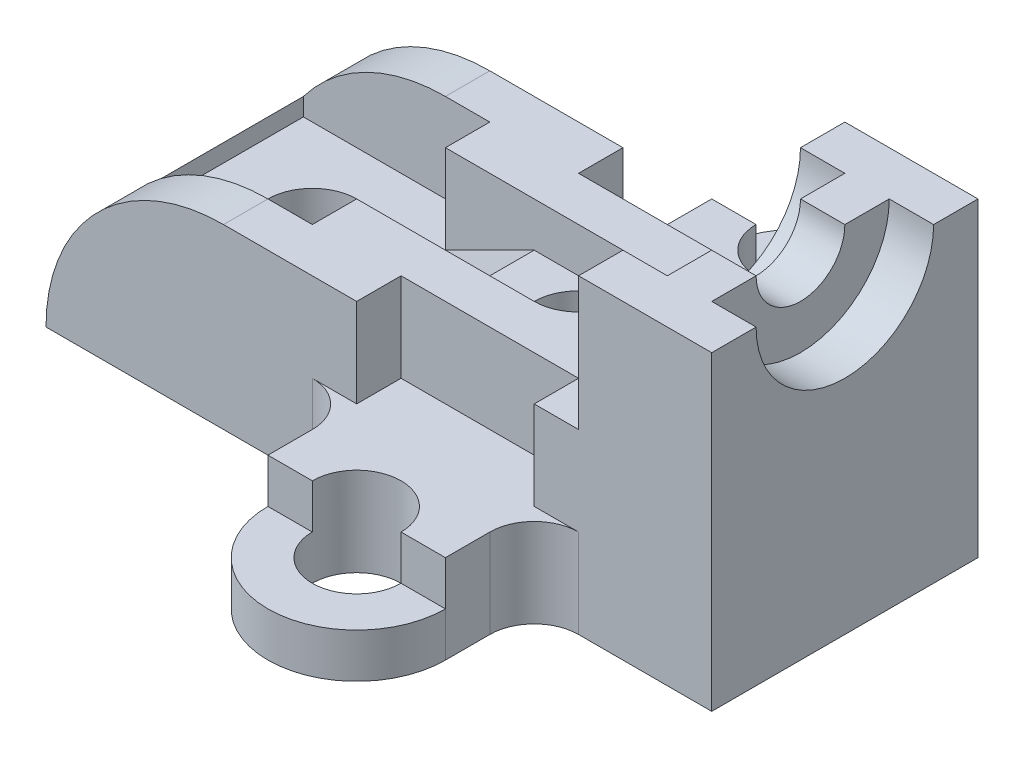
from build123d import *

# Parameters (mm, degrees)
BOSS_EXTRUDE1_DEPTH = 60
CUT_EXTRUDE1_DEPTH  = 10
CUT_EXTRUDE2_DEPTH  = 10
CUT_EXTRUDE3_DEPTH  = 30
SKETCH7_R           = 10
CUT_EXTRUDE5_DEPTH  = 75
SKETCH8_R           = 10
CUT_EXTRUDE6_DEPTH  = 75
SKETCH9_W           = 42
SKETCH9_H           = 40
CUT_EXTRUDE8_DEPTH  = 65
CUT_EXTRUDE9_DEPTH  = 10
CUT_EXTRUDE10_DEPTH = 20
SKETCH12_W          = 40
SKETCH12_H          = 10
CUT_EXTRUDE11_DEPTH = 20
BOSS_EXTRUDE2_DEPTH = 20
SKETCH14_R          = 10
CUT_EXTRUDE14_DEPTH = 20
CUT_EXTRUDE15_DEPTH = 10
BOSS_EXTRUDE3_DEPTH = 20
SKETCH18_R          = 10
CUT_EXTRUDE16_DEPTH = 20
CUT_EXTRUDE17_DEPTH = 10


with BuildPart() as part:
    # Sketch2 → Boss-Extrude1 (new body)
    with BuildSketch(Plane.XY):
        with BuildLine():
            Line((0, 0), (150, 0))
            Line((150, 0), (150, 70))
            Line((150, 70), (120, 70))
            Line((120, 70), (120, 40))
            Line((120, 40), (40, 40))
            ThreePointArc((40, 40), (11.715728753, 28.284271247), (0, 0))
        make_face()
    extrude(amount=BOSS_EXTRUDE1_DEPTH)

    # Sketch4 → Cut-Extrude1 (cut)
    with BuildSketch(Plane(origin=(150, 0, 0), x_dir=(0, 0, -1), z_dir=(1, 0, 0))):
        with BuildLine():
            Line((-50, 70), (-40, 70))
            ThreePointArc((-40, 70), (-30, 60), (-20, 70))
            Line((-20, 70), (-10, 70))
            ThreePointArc((-10, 70), (-30, 50), (-50, 70))
        make_face()
    extrude(amount=-CUT_EXTRUDE1_DEPTH, mode=Mode.SUBTRACT)

    # Sketch5 → Cut-Extrude2 (cut)
    with BuildSketch(Plane.ZY.offset(-120)):
        with BuildLine():
            Line((10, 70), (20, 70))
            ThreePointArc((20, 70), (30, 60), (40, 70))
            Line((40, 70), (50, 70))
            ThreePointArc((50, 70), (30, 50), (10, 70))
        make_face()
    extrude(amount=-CUT_EXTRUDE2_DEPTH, mode=Mode.SUBTRACT)

    # Sketch6 → Cut-Extrude3 (cut)
    with BuildSketch(Plane.ZY.offset(-120)):
        with BuildLine():
            Line((20, 70), (40, 70))
            ThreePointArc((40, 70), (30, 60), (20, 70))
        make_face()
    extrude(amount=-CUT_EXTRUDE3_DEPTH, mode=Mode.SUBTRACT)

    # Sketch7 → Cut-Extrude5 (cut)
    with BuildSketch(Plane(origin=(0, 40, 0), x_dir=(1, 0, 0), z_dir=(0, 1, 0))):
        with Locations((90, -30)):
            Circle(SKETCH7_R)
    extrude(amount=-CUT_EXTRUDE5_DEPTH, mode=Mode.SUBTRACT)

    # Sketch8 → Cut-Extrude6 (cut)
    with BuildSketch(Plane.XZ):
        with Locations((30, 30)):
            Circle(SKETCH8_R)
    extrude(amount=-CUT_EXTRUDE6_DEPTH, mode=Mode.SUBTRACT)

    # Sketch9 → Cut-Extrude8 (cut)
    with BuildSketch(Plane(origin=(0, 20, 0), x_dir=(1, 0, 0), z_dir=(0, 1, 0))):
        with Locations((29, -30)):
            Rectangle(SKETCH9_W, SKETCH9_H)
    extrude(amount=CUT_EXTRUDE8_DEPTH, mode=Mode.SUBTRACT)

    # Sketch10 → Cut-Extrude9 (cut)
    with BuildSketch(Plane(origin=(0, 40, 0), x_dir=(1, 0, 0), z_dir=(0, 1, 0))):
        with BuildLine():
            Line((90, -20), (50, -20))
            Line((50, -20), (50, -40))
            Line((50, -40), (90, -40))
            ThreePointArc((90, -40), (80, -30), (90, -20))
        make_face()
    extrude(amount=-CUT_EXTRUDE9_DEPTH, mode=Mode.SUBTRACT)

    # Sketch11 → Cut-Extrude10 (cut)
    with BuildSketch(Plane.XY.offset(20)):
        Polygon((50, 20), (70, 30), (50, 30), align=None)
    extrude(amount=CUT_EXTRUDE10_DEPTH, mode=Mode.SUBTRACT)

    # Sketch12 → Cut-Extrude11 (cut)
    with BuildSketch(Plane(origin=(0, 40, 0), x_dir=(1, 0, 0), z_dir=(0, 1, 0))):
        with Locations((90, -55)):
            Rectangle(SKETCH12_W, SKETCH12_H)
        with Locations((90, -5)):
            Rectangle(SKETCH12_W, SKETCH12_H)
    extrude(amount=-CUT_EXTRUDE11_DEPTH, mode=Mode.SUBTRACT)

    # Sketch13 → Boss-Extrude2 (add)
    with BuildSketch(Plane(origin=(0, 0, 0), x_dir=(1, 0, 0), z_dir=(0, 1, 0))):
        with BuildLine():
            Line((70, -70), (70, -80))
            ThreePointArc((70, -80), (90, -100), (110, -80))
            Line((110, -80), (110, -70))
            ThreePointArc((110, -70), (112.928932188, -62.928932188), (120, -60))
            Line((120, -60), (60, -60))
            ThreePointArc((60, -60), (67.071067812, -62.928932188), (70, -70))
        make_face()
    extrude(amount=BOSS_EXTRUDE2_DEPTH)

    # Sketch14 → Cut-Extrude14 (cut)
    with BuildSketch(Plane(origin=(0, 20, 0), x_dir=(1, 0, 0), z_dir=(0, 1, 0))):
        with Locations((90, -80)):
            Circle(SKETCH14_R)
    extrude(amount=-CUT_EXTRUDE14_DEPTH, mode=Mode.SUBTRACT)

    # Sketch15 → Cut-Extrude15 (cut)
    with BuildSketch(Plane(origin=(0, 20, 0), x_dir=(1, 0, 0), z_dir=(0, 1, 0))):
        with BuildLine():
            Line((70, -80), (80, -80))
            ThreePointArc((80, -80), (90, -90), (100, -80))
            Line((100, -80), (110, -80))
            ThreePointArc((110, -80), (90, -100), (70, -80))
        make_face()
    extrude(amount=-CUT_EXTRUDE15_DEPTH, mode=Mode.SUBTRACT)

    # Sketch17 → Boss-Extrude3 (add)
    with BuildSketch(Plane.XZ):
        with BuildLine():
            Line((110, -10), (110, -20))
            ThreePointArc((110, -20), (90, -40), (70, -20))
            Line((70, -20), (70, -10))
            ThreePointArc((70, -10), (67.071067812, -2.928932188), (60, 0))
            Line((60, 0), (120, 0))
            ThreePointArc((120, 0), (112.928932188, -2.928932188), (110, -10))
        make_face()
    extrude(amount=-BOSS_EXTRUDE3_DEPTH)

    # Sketch18 → Cut-Extrude16 (cut)
    with BuildSketch(Plane(origin=(0, 20, 0), x_dir=(1, 0, 0), z_dir=(0, 1, 0))):
        with Locations((90, 20)):
            Circle(SKETCH18_R)
    extrude(amount=-CUT_EXTRUDE16_DEPTH, mode=Mode.SUBTRACT)

    # Sketch19 → Cut-Extrude17 (cut)
    with BuildSketch(Plane(origin=(0, 20, 0), x_dir=(1, 0, 0), z_dir=(0, 1, 0))):
        with BuildLine():
            Line((100, 20), (110, 20))
            ThreePointArc((110, 20), (90, 40), (70, 20))
            Line((70, 20), (80, 20))
            ThreePointArc((80, 20), (90, 30), (100, 20))
        make_face()
    extrude(amount=-CUT_EXTRUDE17_DEPTH, mode=Mode.SUBTRACT)


solid = part.part
